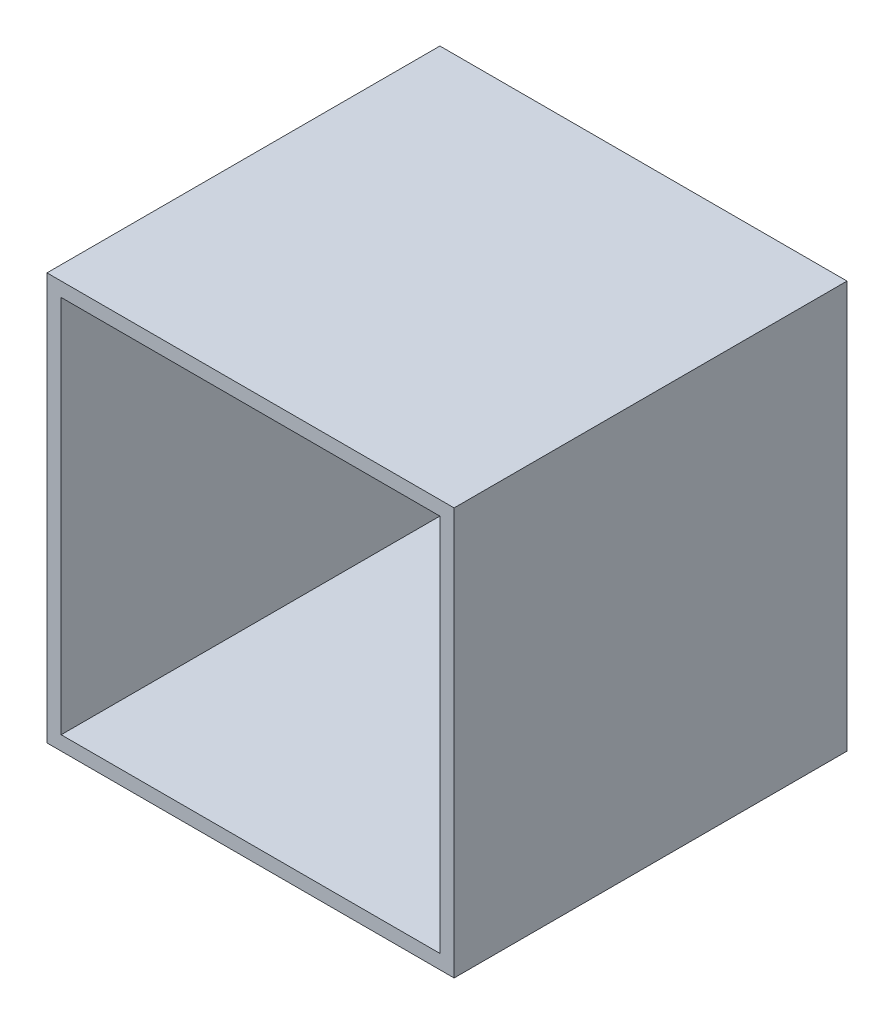
from build123d import *

# Parameters (mm, degrees)
SKETCH1_W           = 86
SKETCH1_H           = 86
SKETCH1_W_2         = 80
SKETCH1_H_2         = 80
BOSS_EXTRUDE1_DEPTH = 80
SKETCH2_W           = 86
SKETCH2_H           = 86
BOSS_EXTRUDE2_DEPTH = 3


with BuildPart() as part:
    # Sketch1 → Boss-Extrude1 (new body)
    with BuildSketch(Plane.XY):
        Rectangle(SKETCH1_W, SKETCH1_H)
        Rectangle(SKETCH1_W_2, SKETCH1_H_2, mode=Mode.SUBTRACT)
    extrude(amount=BOSS_EXTRUDE1_DEPTH)

    # Sketch2 → Boss-Extrude2 (add)
    with BuildSketch(Plane(origin=(0, 0, 0), x_dir=(-1, 0, 0), z_dir=(0, 0, -1))):
        Rectangle(SKETCH2_W, SKETCH2_H)
    extrude(amount=BOSS_EXTRUDE2_DEPTH)


solid = part.part
